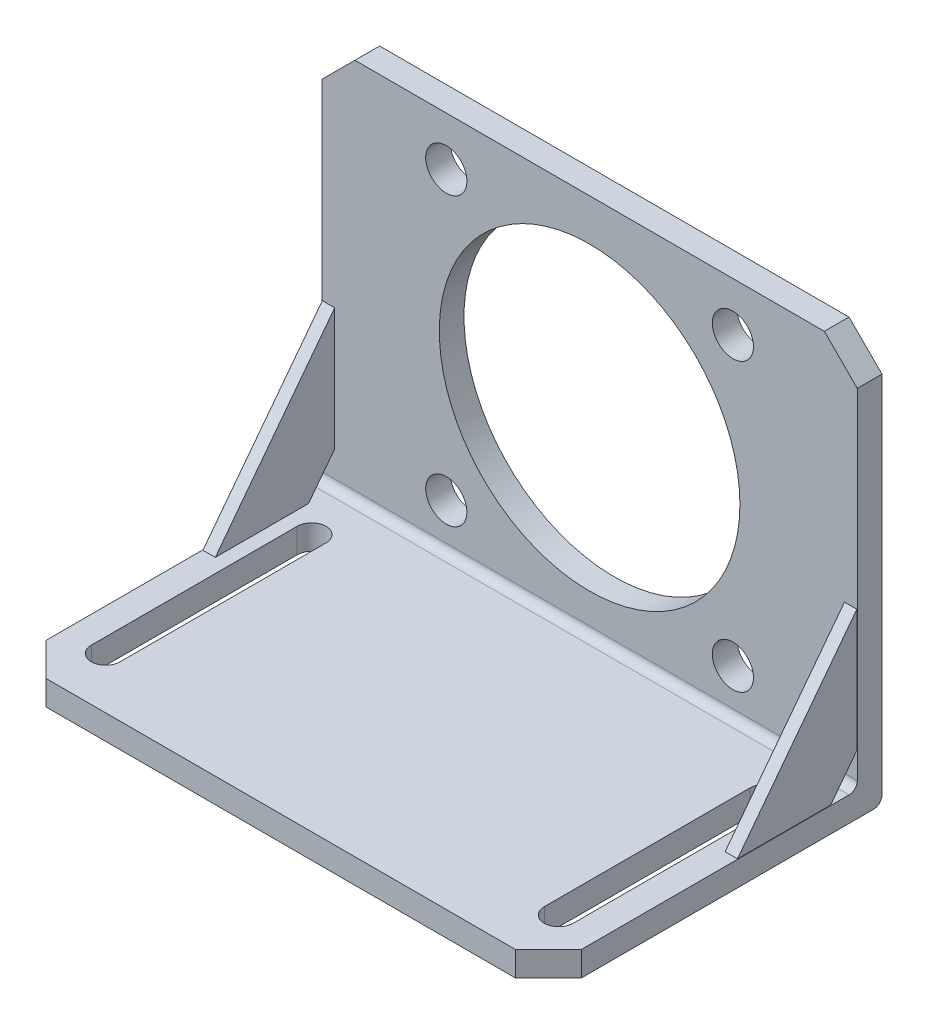
from build123d import *

# Parameters (mm, degrees)
SKETCH1_W           = 130
SKETCH1_H           = 98.5
SKETCH1_R           = 36.5
SKETCH1_R_2         = 5
BOSS_EXTRUDE1_DEPTH = 6
SKETCH2_W           = 130
SKETCH2_H           = 6
BOSS_EXTRUDE2_DEPTH = 75
CHAMFER1_SIZE       = 8
CUT_EXTRUDE1_DEPTH  = 7
BOSS_EXTRUDE3_START = -0.1
BOSS_EXTRUDE3_DEPTH = 3
BOSS_EXTRUDE4_START = -0.1
BOSS_EXTRUDE4_DEPTH = 3
FILLET1_R           = 2


with BuildPart() as part:
    # Sketch1 → Boss-Extrude1 (new body)
    with BuildSketch(Plane.XY):
        with Locations((-0.4, 43.207953426)):
            Rectangle(SKETCH1_W, SKETCH1_H)
        with Locations((-0.4, 45.807953426)):
            Circle(SKETCH1_R, mode=Mode.SUBTRACT)
        with Locations((-35.2, 80.607953426)):
            Circle(SKETCH1_R_2, mode=Mode.SUBTRACT)
        with Locations((34.4, 80.607953426)):
            Circle(SKETCH1_R_2, mode=Mode.SUBTRACT)
        with Locations((34.4, 11.007953426)):
            Circle(SKETCH1_R_2, mode=Mode.SUBTRACT)
        with Locations((-35.2, 11.007953426)):
            Circle(SKETCH1_R_2, mode=Mode.SUBTRACT)
    extrude(amount=BOSS_EXTRUDE1_DEPTH)

    # Sketch2 → Boss-Extrude2 (add)
    with BuildSketch(Plane.XY.offset(6)):
        with Locations((-0.4, -3.042046574)):
            Rectangle(SKETCH2_W, SKETCH2_H)
    extrude(amount=BOSS_EXTRUDE2_DEPTH)

    # Chamfer1
    chamfer1_edges = [part.edges().sort_by_distance(p)[0] for p in [
        (-65.4, -3.042046574, 81),
        (64.6, -3.042046574, 81),
        (-65.4, 92.457953426, 3),
        (64.6, 92.457953426, 3),
    ]]
    chamfer(chamfer1_edges, length=CHAMFER1_SIZE)

    # Sketch3 → Cut-Extrude1 (cut, through all)
    with BuildSketch(Plane(origin=(0, -0.042046574, 0), x_dir=(1, 0, 0), z_dir=(0, 1, 0))):
        with BuildLine():
            Line((-58.9, -68.5), (-58.9, -18.5))
            ThreePointArc((-58.9, -18.5), (-55.4, -15), (-51.9, -18.5))
            Line((-51.9, -18.5), (-51.9, -68.5))
            ThreePointArc((-51.9, -68.5), (-55.4, -72), (-58.9, -68.5))
        make_face()
        with BuildLine():
            Line((58.1, -68.5), (58.1, -18.5))
            ThreePointArc((58.1, -18.5), (54.6, -15), (51.1, -18.5))
            Line((51.1, -18.5), (51.1, -68.5))
            ThreePointArc((51.1, -68.5), (54.6, -72), (58.1, -68.5))
        make_face()
    extrude(amount=-CUT_EXTRUDE1_DEPTH, mode=Mode.SUBTRACT)

    # Sketch4 → Boss-Extrude3 (add)
    with BuildSketch(Plane.ZY.offset(65.4).offset(BOSS_EXTRUDE3_START)):
        Polygon((6, 37.957953426), (35, -0.042046574), (12.357101974, -0.042046574), (6, 8.287949116), align=None)
    extrude(amount=-BOSS_EXTRUDE3_DEPTH)

    # Sketch5 → Boss-Extrude4 (add)
    with BuildSketch(Plane(origin=(64.6, 0, 0), x_dir=(0, 0, -1), z_dir=(1, 0, 0)).offset(BOSS_EXTRUDE4_START)):
        Polygon((-6, 8.287949116), (-6, 37.957953426), (-35, -0.042046574), (-12.357101974, -0.042046574), align=None)
    extrude(amount=-BOSS_EXTRUDE4_DEPTH)

    # Fillet1
    fillet1_edges = [part.edges().sort_by_distance(p)[0] for p in [
        (-0.4, -0.042046574, 6),
        (-0.4, -6.042046574, 0),
    ]]
    fillet(fillet1_edges, radius=FILLET1_R)


solid = part.part
